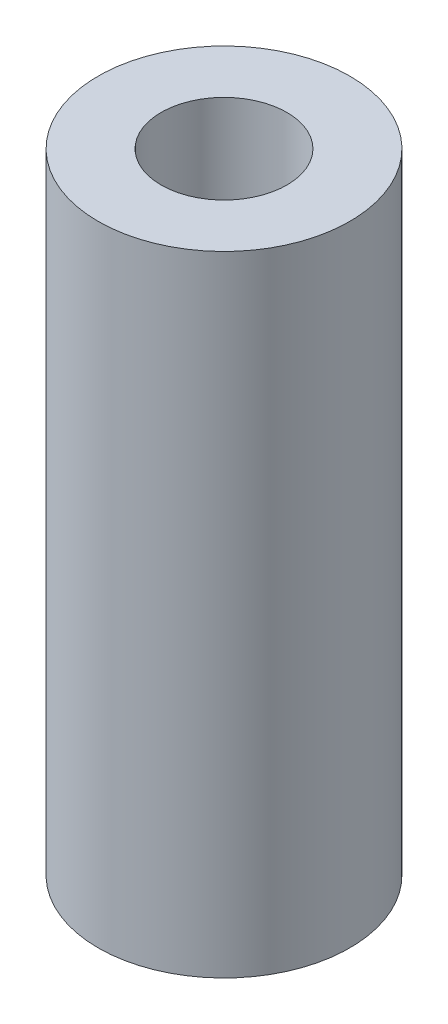
from build123d import *

# Parameters (mm, degrees)
SKETCH1_R           = 5
SKETCH1_R_2         = 2.5
BOSS_EXTRUDE1_DEPTH = 25


with BuildPart() as part:
    # Sketch1 → Boss-Extrude1 (new body)
    with BuildSketch(Plane(origin=(0, 0, 0), x_dir=(1, 0, 0), z_dir=(0, 1, 0))):
        Circle(SKETCH1_R)
        Circle(SKETCH1_R_2, mode=Mode.SUBTRACT)
    extrude(amount=BOSS_EXTRUDE1_DEPTH)


solid = part.part
